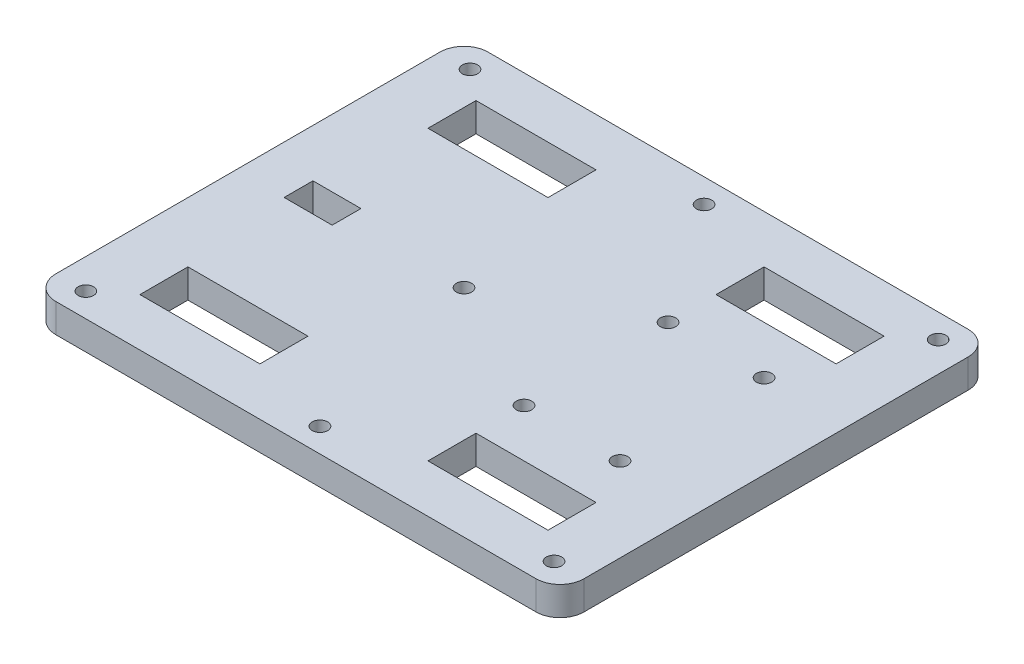
from build123d import *

# Parameters (mm, degrees)
SKETCH1_W                = 110
SKETCH1_H                = 90
BOSS_EXTRUDE1_DEPTH      = 6
SKETCH2_W                = 25
SKETCH2_H                = 10
CUT_EXTRUDE1_DEPTH       = 7
MIRROR2_COPY_1_SKETCH_W  = 25
MIRROR2_COPY_1_SKETCH_H  = 10
MIRROR2_COPY_1_DEPTH     = 7
M3_CLEARANCE_HOLE1_D     = 3.2
M3_CLEARANCE_HOLE2_D     = 3.2
FILLET1_R                = 5
SKETCH62_W               = 10
SKETCH62_H               = 6
CUT_EXTRUDE12_DEPTH      = 4
CUT_EXTRUDE12_DEPTH_BACK = 4


with BuildPart() as part:
    # Sketch1 → Boss-Extrude1 (new body)
    with BuildSketch(Plane(origin=(0, 0, 0), x_dir=(1, 0, 0), z_dir=(0, 1, 0))):
        Rectangle(SKETCH1_W, SKETCH1_H)
    extrude(amount=BOSS_EXTRUDE1_DEPTH)

    # Sketch2 → Cut-Extrude1 (cut, through all)
    with BuildSketch(Plane(origin=(0, 6, 0), x_dir=(1, 0, 0), z_dir=(0, 1, 0))):
        with Locations((30, 30)):
            Rectangle(SKETCH2_W, SKETCH2_H)
    cut_extrude1 = extrude(amount=-CUT_EXTRUDE1_DEPTH, mode=Mode.SUBTRACT)

    # Mirror1: Cut-Extrude1 across plane
    add(cut_extrude1.mirror(Plane.XY), mode=Mode.SUBTRACT)

    # Mirror2: Cut-Extrude1 across plane
    add(cut_extrude1.mirror(Plane(origin=(0, 0, 0), x_dir=(0, 0, 1), z_dir=(1, 0, 0))), mode=Mode.SUBTRACT)

    # Mirror2 copy 1 sketch → Mirror2 copy 1 (cut, through all)
    with BuildSketch(Plane(origin=(0, 6, 0), x_dir=(-1, 0, 0), z_dir=(0, 1, 0))):
        with Locations((30, 30)):
            Rectangle(MIRROR2_COPY_1_SKETCH_W, MIRROR2_COPY_1_SKETCH_H)
    extrude(amount=-MIRROR2_COPY_1_DEPTH, mode=Mode.SUBTRACT)

    # M3 Clearance Hole1 (through all)
    with Locations(Plane(origin=(0, 6, 0), x_dir=(1, 0, 0), z_dir=(0, 1, 0))):
        with Locations((17.5, 15), (37.5, 15), (17.5, -15), (37.5, -15)):
            Hole(M3_CLEARANCE_HOLE1_D / 2)

    # M3 Clearance Hole2 (through all)
    with Locations(Plane(origin=(0, 6, 0), x_dir=(1, 0, 0), z_dir=(0, 1, 0))):
        with Locations((48.75, 40), (0, 40), (-48.75, 40), (-48.75, -40), (0, -40), (48.75, -40), (-10, 0)):
            Hole(M3_CLEARANCE_HOLE2_D / 2)

    # Fillet1
    fillet1_edges = [part.edges().sort_by_distance(p)[0] for p in [
        (55, 3, 45),
        (-55, 3, 45),
        (-55, 3, -45),
        (55, 3, -45),
    ]]
    fillet(fillet1_edges, radius=FILLET1_R)

    # Sketch62 → Cut-Extrude12 (cut, two sides)
    with BuildSketch(Plane(origin=(-39.232221392, 3, -44.54), x_dir=(-1, 0, 0), z_dir=(0, -1, 0))) as cut_extrude12_sk:
        with Locations((0.767778608, -44)):
            Rectangle(SKETCH62_W, SKETCH62_H)
    extrude(amount=CUT_EXTRUDE12_DEPTH, mode=Mode.SUBTRACT)
    extrude(cut_extrude12_sk.sketch, amount=-CUT_EXTRUDE12_DEPTH_BACK, mode=Mode.SUBTRACT)


solid = part.part
